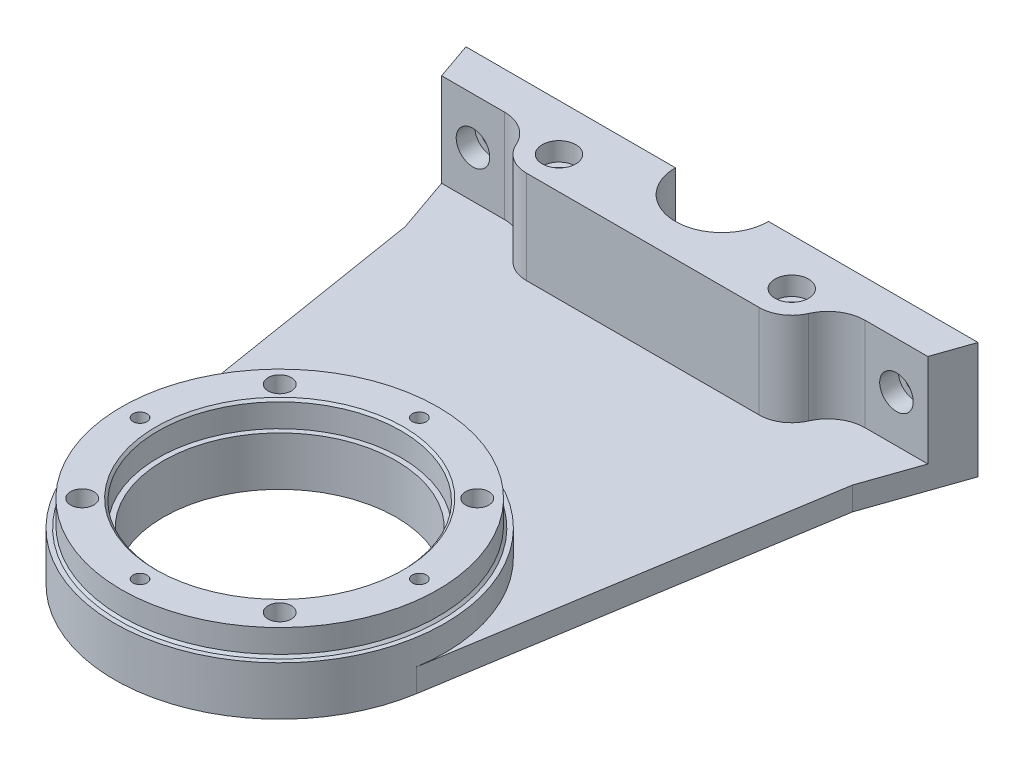
from build123d import *

# Parameters (mm, degrees)
SKETCH1_R           = 34
SKETCH1_R_2         = 26.1
BOSS_EXTRUDE1_DEPTH = 5.5
SKETCH2_R           = 35.5
SKETCH2_R_2         = 25
BOSS_EXTRUDE2_DEPTH = 5.5
SKETCH3_R           = 25
SKETCH3_R_2         = 2.2
BOSS_EXTRUDE3_DEPTH = 5
CHAMFER1_SIZE       = 0.5
SKETCH5_R           = 2.5
SKETCH5_R_2         = 1.5
CUT_EXTRUDE1_DEPTH  = 17
SKETCH6_R           = 2.2
BOSS_EXTRUDE4_DEPTH = 20
SKETCH7_R           = 3.6
CUT_EXTRUDE2_DEPTH  = 4
SKETCH8_R           = 2.2
CUT_EXTRUDE3_DEPTH  = 8
SKETCH9_R           = 3.6
CUT_EXTRUDE4_DEPTH  = 4


with BuildPart() as part:
    # Sketch1 → Boss-Extrude1 (new body)
    with BuildSketch(Plane(origin=(0, 0, 0), x_dir=(1, 0, 0), z_dir=(0, 1, 0))):
        Circle(SKETCH1_R)
        Circle(SKETCH1_R_2, mode=Mode.SUBTRACT)
    extrude(amount=BOSS_EXTRUDE1_DEPTH)

    # Sketch2 → Boss-Extrude2 (add)
    with BuildSketch(Plane(origin=(0, 0, 0), x_dir=(-1, 0, 0), z_dir=(0, -1, 0))):
        Circle(SKETCH2_R)
        Circle(SKETCH2_R_2, mode=Mode.SUBTRACT)
    extrude(amount=BOSS_EXTRUDE2_DEPTH)

    # Sketch3 → Boss-Extrude3 (add)
    with BuildSketch(Plane.XZ.offset(5.5)):
        with BuildLine():
            Line((-55, -95), (-10, -95))
            ThreePointArc((-10, -95), (0, -85), (10, -95))
            Line((10, -95), (55, -95))
            Line((55, -95), (48.055, -75))
            Line((48.055, -75), (35.047098592, 5.652510971))
            ThreePointArc((35.047098592, 5.652510971), (0, 35.5), (-35.047098592, 5.652510971))
            Line((-35.047098592, 5.652510971), (-48.055, -75))
            Line((-48.055, -75), (-55, -95))
        make_face()
        Circle(SKETCH3_R, mode=Mode.SUBTRACT)
        with Locations((-25, -85)):
            Circle(SKETCH3_R_2, mode=Mode.SUBTRACT)
        with Locations((25, -85)):
            Circle(SKETCH3_R_2, mode=Mode.SUBTRACT)
    extrude(amount=BOSS_EXTRUDE3_DEPTH)

    # Chamfer1
    chamfer1_edges = [part.edges().sort_by_distance(p)[0] for p in [
        (-34, 0, 0),
        (-26.1, 5.5, 0),
    ]]
    chamfer(chamfer1_edges, length=CHAMFER1_SIZE)

    # Sketch5 → Cut-Extrude1 (cut, through all)
    with BuildSketch(Plane(origin=(0, 5.5, 0), x_dir=(1, 0, 0), z_dir=(0, 1, 0))):
        with Locations((21.213203436, 21.213203436)):
            Circle(SKETCH5_R)
        with Locations((0, 30)):
            Circle(SKETCH5_R_2)
        with Locations((30, 0)):
            Circle(SKETCH5_R_2)
        with Locations((0, -30)):
            Circle(SKETCH5_R_2)
        with Locations((-30, 0)):
            Circle(SKETCH5_R_2)
        with Locations((21.213203436, -21.213203436)):
            Circle(SKETCH5_R)
        with Locations((-21.213203436, -21.213203436)):
            Circle(SKETCH5_R)
        with Locations((-21.213203436, 21.213203436)):
            Circle(SKETCH5_R)
    extrude(amount=-CUT_EXTRUDE1_DEPTH, mode=Mode.SUBTRACT)

    # Sketch6 → Boss-Extrude4 (add)
    with BuildSketch(Plane(origin=(0, -5.5, 0), x_dir=(1, 0, 0), z_dir=(0, 1, 0))):
        with BuildLine():
            Line((52.222, 87), (55, 95))
            Line((55, 95), (10, 95))
            ThreePointArc((10, 95), (0, 85), (-10, 95))
            Line((-10, 95), (-55, 95))
            Line((-55, 95), (-52.222, 87))
            Line((-52.222, 87), (-38.747727085, 87))
            ThreePointArc((-38.747727085, 87), (-34.365946625, 85.693280212), (-31.415605973, 82.2))
            ThreePointArc((-31.415605973, 82.2), (-28.834057903, 79.143379814), (-25, 78))
            Line((-25, 78), (25, 78))
            ThreePointArc((25, 78), (28.834057903, 79.143379814), (31.415605973, 82.2))
            ThreePointArc((31.415605973, 82.2), (34.365946625, 85.693280212), (38.747727085, 87))
            Line((38.747727085, 87), (52.222, 87))
        make_face()
        with Locations((-25, 85)):
            Circle(SKETCH6_R, mode=Mode.SUBTRACT)
        with Locations((25, 85)):
            Circle(SKETCH6_R, mode=Mode.SUBTRACT)
    extrude(amount=BOSS_EXTRUDE4_DEPTH)

    # Sketch7 → Cut-Extrude2 (cut)
    with BuildSketch(Plane(origin=(0, 14.5, 0), x_dir=(1, 0, 0), z_dir=(0, 1, 0))):
        with Locations((25, 85)):
            Circle(SKETCH7_R)
        with Locations((-25, 85)):
            Circle(SKETCH7_R)
    extrude(amount=-CUT_EXTRUDE2_DEPTH, mode=Mode.SUBTRACT)

    # Sketch8 → Cut-Extrude3 (cut)
    with BuildSketch(Plane.XY.offset(-87)):
        with Locations((-45.484863542, 4.5)):
            Circle(SKETCH8_R)
        with Locations((45.484863542, 4.5)):
            Circle(SKETCH8_R)
    extrude(amount=-CUT_EXTRUDE3_DEPTH, mode=Mode.SUBTRACT)

    # Sketch9 → Cut-Extrude4 (cut)
    with BuildSketch(Plane.XY.offset(-87)):
        with Locations((-45.484863542, 4.5)):
            Circle(SKETCH9_R)
        with Locations((45.484863542, 4.5)):
            Circle(SKETCH9_R)
    extrude(amount=-CUT_EXTRUDE4_DEPTH, mode=Mode.SUBTRACT)


solid = part.part
